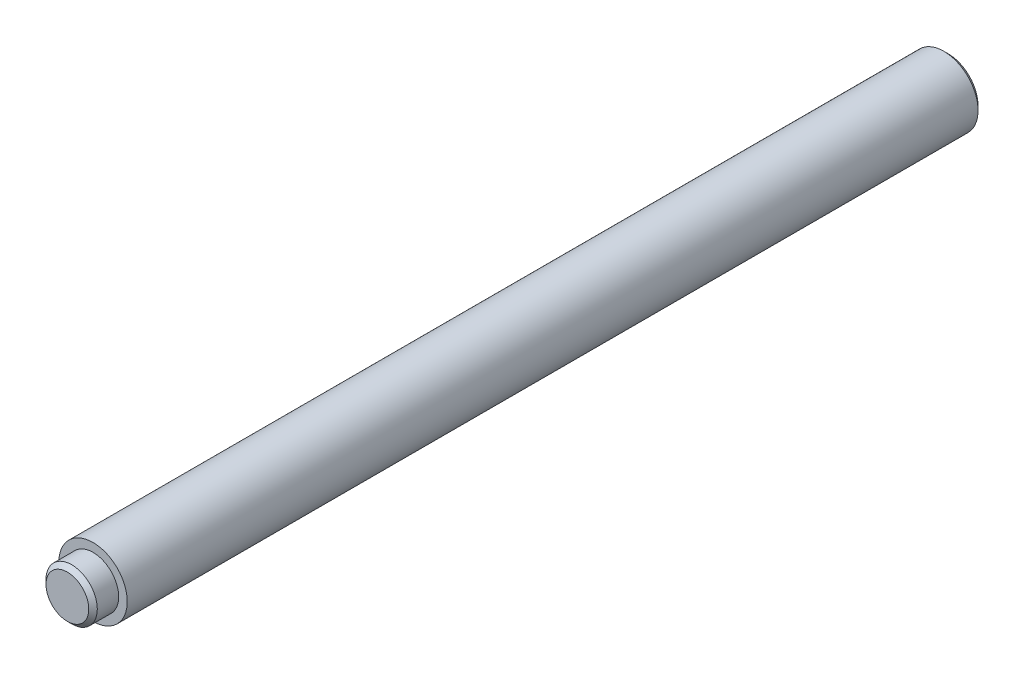
from build123d import *

# Parameters (mm, degrees)
CHAMFER1_SIZE = 0.5


with BuildPart() as part:
    # Sketch1 → Revolve1 (revolve)
    with BuildSketch(Plane(origin=(0, 0, 0), x_dir=(0, 0, -1), z_dir=(1, 0, 0))):
        Polygon((-3, 0), (100, 0), (100, 4), (0, 4), (0, 3), (-3, 3), align=None)
    revolve(axis=Axis((0, 0, 3), (0, 0, 1)))

    # Chamfer1
    chamfer1_edges = [part.edges().sort_by_distance(p)[0] for p in [
        (0, -4, -100),
        (0, -3, 3),
    ]]
    chamfer(chamfer1_edges, length=CHAMFER1_SIZE)


solid = part.part
